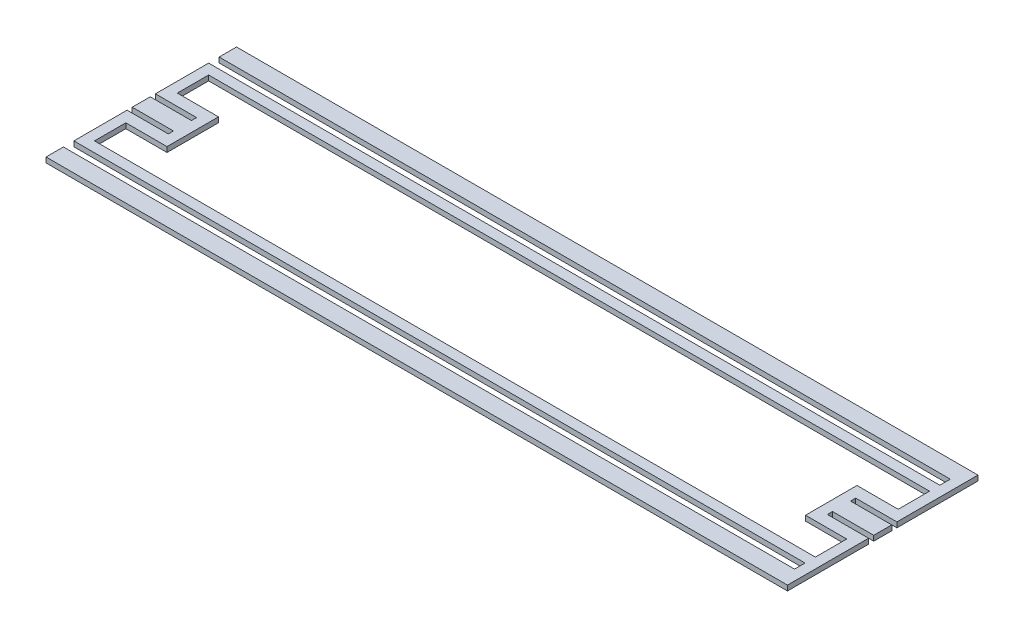
from build123d import *

# Parameters (mm, degrees)
BOSS_EXTRUDE1_DEPTH = 1.5875


with BuildPart() as part:
    # Sketch1 → Boss-Extrude1 (new body, symmetric)
    with BuildSketch(Plane(origin=(0, 0, 0), x_dir=(1, 0, 0), z_dir=(0, 1, 0))):
        Polygon((222.25, 41.544875), (-228.6, 41.544875), (-228.6, 8.73125), (-222.25, 8.73125), (-203.2, 8.73125), (-203.2, 5.55625), (-222.25, 5.55625), (-228.6, 5.55625), (-228.6, -5.55625), (-222.25, -5.55625), (-203.2, -5.55625), (-203.2, -8.73125), (-222.25, -8.73125), (-228.6, -8.73125), (-228.6, -41.544875), (222.25, -41.544875), (222.25, -48.021875), (-228.6, -48.021875), (-228.6, -58.7375), (190.5, -58.7375), (228.6, -58.7375), (228.6, -8.73125), (222.25, -8.73125), (203.2, -8.73125), (203.2, -5.55625), (222.25, -5.55625), (228.6, -5.55625), (228.6, 5.55625), (222.25, 5.55625), (203.2, 5.55625), (203.2, 8.73125), (222.25, 8.73125), (228.6, 8.73125), (228.6, 58.7375), (190.5, 58.7375), (-228.6, 58.7375), (-228.6, 48.021875), (222.25, 48.021875), align=None)
        Polygon((222.25, 35.194875), (222.25, 15.875), (196.85, 15.875), (196.85, -15.875), (222.25, -15.875), (222.25, -35.194875), (-222.25, -35.194875), (-222.25, -15.875), (-196.85, -15.875), (-196.85, 15.875), (-222.25, 15.875), (-222.25, 35.194875), align=None, mode=Mode.SUBTRACT)
    extrude(amount=BOSS_EXTRUDE1_DEPTH, both=True)


solid = part.part
